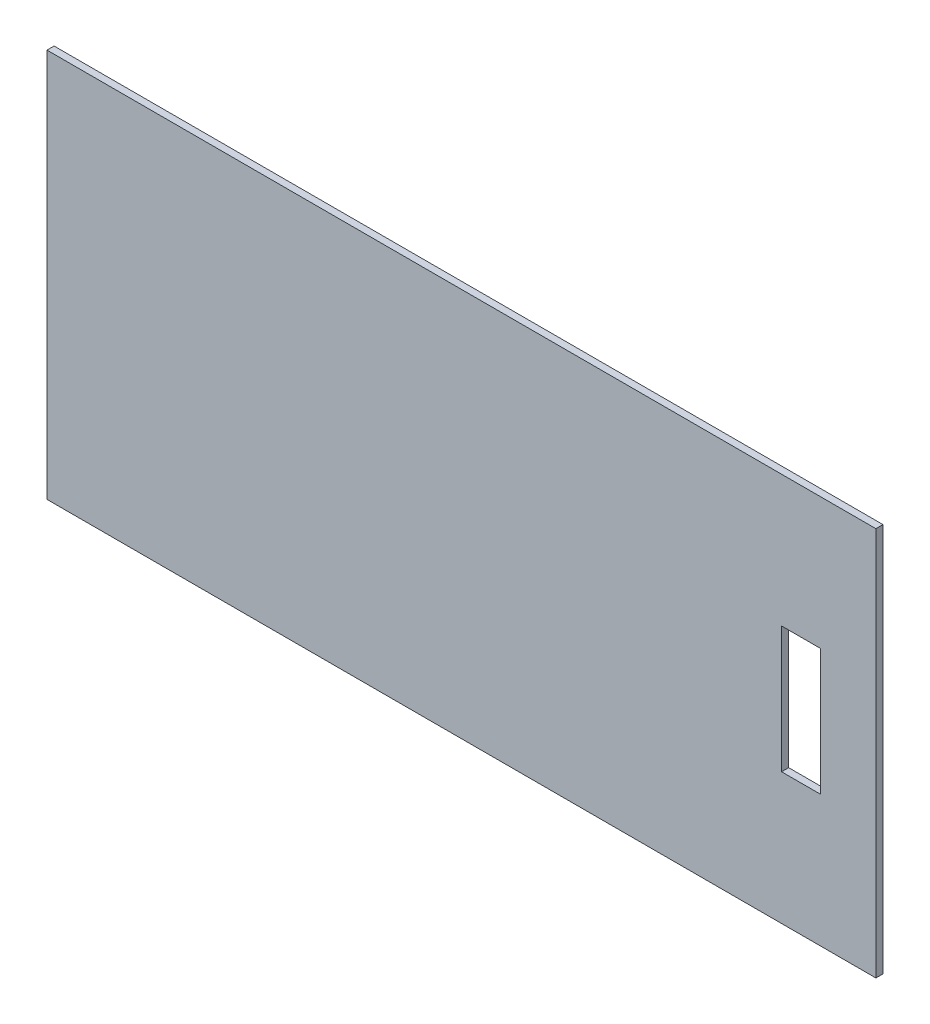
from build123d import *

# Parameters (mm, degrees)
SKETCH1_W           = 409
SKETCH1_H           = 192
BOSS_EXTRUDE1_DEPTH = 3.5
SKETCH2_W           = 19.2
SKETCH2_H           = 62.3
CUT_EXTRUDE1_DEPTH  = 4.5


with BuildPart() as part:
    # Sketch1 → Boss-Extrude1 (new body)
    with BuildSketch(Plane.XY):
        with Locations((12.113240418, -24.033101045)):
            Rectangle(SKETCH1_W, SKETCH1_H)
    extrude(amount=BOSS_EXTRUDE1_DEPTH)

    # Sketch2 → Cut-Extrude1 (cut, through all)
    with BuildSketch(Plane.XY.offset(3.5)):
        with Locations((179.663240418, -24.033101045)):
            Rectangle(SKETCH2_W, SKETCH2_H)
    extrude(amount=-CUT_EXTRUDE1_DEPTH, mode=Mode.SUBTRACT)


solid = part.part
